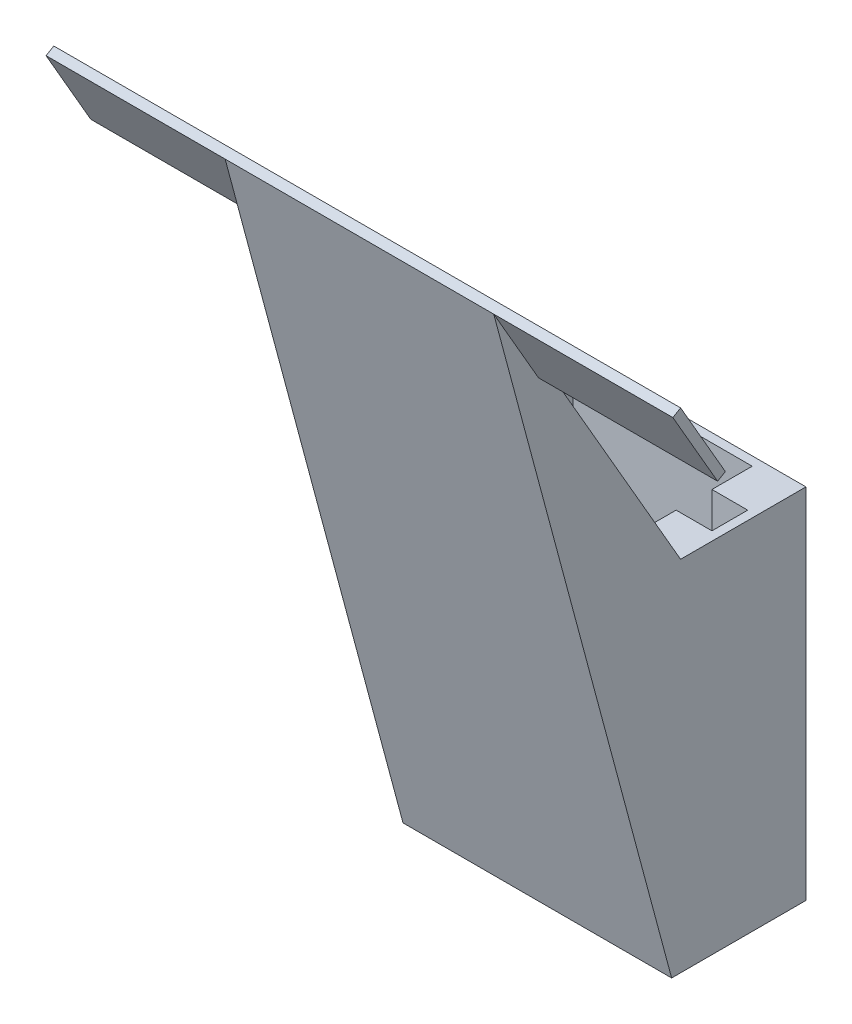
from build123d import *

# Parameters (mm, degrees)
SKIZZE1_W                       = 15
SKIZZE1_H                       = 7.5
AUFSATZ_LINEAR_AUSTRAGEN1_DEPTH = 20
AUFSATZ_LINEAR_AUSTRAGEN2_DEPTH = 15
AUFSATZ_LINEAR_AUSTRAGEN3_DEPTH = 10


with BuildPart() as part:
    # Skizze1 → Aufsatz-Linear austragen1 (new body)
    with BuildSketch(Plane(origin=(0, 0, 0), x_dir=(1, 0, 0), z_dir=(0, 1, 0))):
        Rectangle(SKIZZE1_W, SKIZZE1_H)
        Polygon((-5, 1), (-5, 3.25), (5, 3.25), (5, 1), (7, 1), (7, -1), (5, -1), (5, -3.25), (-5, -3.25), (-5, -1), (-7, -1), (-7, 1), align=None, mode=Mode.SUBTRACT)
    extrude(amount=AUFSATZ_LINEAR_AUSTRAGEN1_DEPTH)

    # Skizze2 → Aufsatz-Linear austragen2 (add)
    with BuildSketch(Plane.ZY.offset(7.5)):
        Polygon((3.75, 0), (3.75, 20), (3.25, 20), (13.25, 37.320508076), (13.683012702, 37.070508076), align=None)
    extrude(amount=-AUFSATZ_LINEAR_AUSTRAGEN2_DEPTH)

    # Skizze4 → Aufsatz-Linear austragen3 (add)
    with BuildSketch(Plane.ZY.offset(7.5)):
        Polygon((10.75, 32.990381057), (11.183012702, 32.740381057), (13.683012702, 37.070508076), (13.25, 37.320508076), align=None)
    aufsatz_linear_austragen3 = extrude(amount=AUFSATZ_LINEAR_AUSTRAGEN3_DEPTH)

    # Spiegeln3: Aufsatz-Linear austragen3 across plane
    add(aufsatz_linear_austragen3.mirror(Plane(origin=(0, 0, 0), x_dir=(0, 0, 1), z_dir=(1, 0, 0))))


solid = part.part
